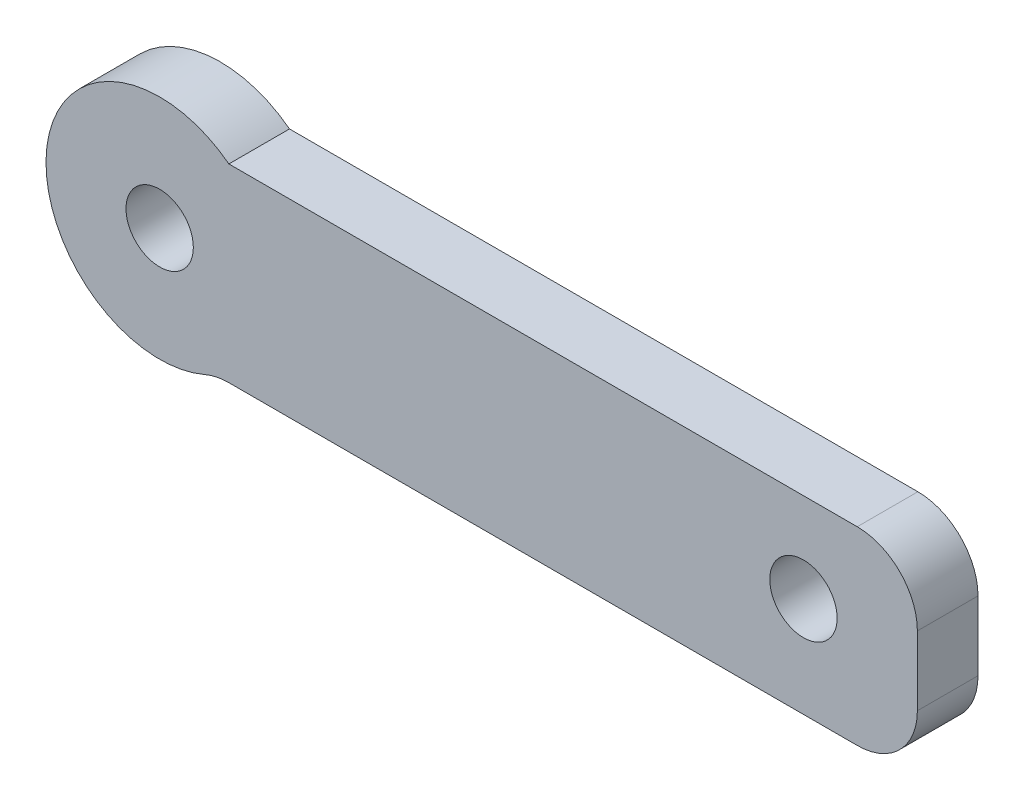
from build123d import *

# Parameters (mm, degrees)
BOSS_EXTRUDE1_DEPTH       = 1.6002
F_0_CLEARANCE_HOLE1_D     = 1.778
F_0_CLEARANCE_HOLE1_DEPTH = 465
F_0_CLEARANCE_HOLE1_TIP   = 0.53416509
F_0_CLEARANCE_HOLE2_D     = 1.778
F_0_CLEARANCE_HOLE2_DEPTH = 465
F_0_CLEARANCE_HOLE2_TIP   = 0.53416509


with BuildPart() as part:
    # Sketch1 → Boss-Extrude1 (new body)
    with BuildSketch(Plane.XY):
        with BuildLine():
            Line((1.827005239, -2.620493359), (18.4125, -2.620493359))
            ThreePointArc((18.4125, -2.620493359), (19.535032015, -2.155525374), (20, -1.032993359))
            Line((20, -1.032993359), (20, 0.792006641))
            ThreePointArc((20, 0.792006641), (19.535032015, 1.914538656), (18.4125, 2.379506641))
            Line((18.4125, 2.379506641), (1.827005239, 2.379506641))
            ThreePointArc((1.827005239, 2.379506641), (-2.977484791, 0.366857357), (1.194771818, -2.75182127))
            ThreePointArc((1.194771818, -2.75182127), (1.504140671, -2.653672053), (1.827005239, -2.620493359))
        make_face()
    extrude(amount=BOSS_EXTRUDE1_DEPTH)

    # #0 Clearance Hole1
    with Locations(Plane.XY.offset(1.6002)):
        with Locations((0, 0)):
            Hole(F_0_CLEARANCE_HOLE1_D / 2, depth=F_0_CLEARANCE_HOLE1_DEPTH)
            with Locations((0, 0, -(F_0_CLEARANCE_HOLE1_DEPTH + F_0_CLEARANCE_HOLE1_TIP / 2))):  # 118° drill point
                Cone(0, F_0_CLEARANCE_HOLE1_D / 2, F_0_CLEARANCE_HOLE1_TIP, mode=Mode.SUBTRACT)

    # #0 Clearance Hole2
    with Locations(Plane(origin=(0, 0, 0), x_dir=(-1, 0, 0), z_dir=(0, 0, -1))):
        with Locations((-16.993218834, 0.022656086)):
            Hole(F_0_CLEARANCE_HOLE2_D / 2, depth=F_0_CLEARANCE_HOLE2_DEPTH)
            with Locations((0, 0, -(F_0_CLEARANCE_HOLE2_DEPTH + F_0_CLEARANCE_HOLE2_TIP / 2))):  # 118° drill point
                Cone(0, F_0_CLEARANCE_HOLE2_D / 2, F_0_CLEARANCE_HOLE2_TIP, mode=Mode.SUBTRACT)


solid = part.part
